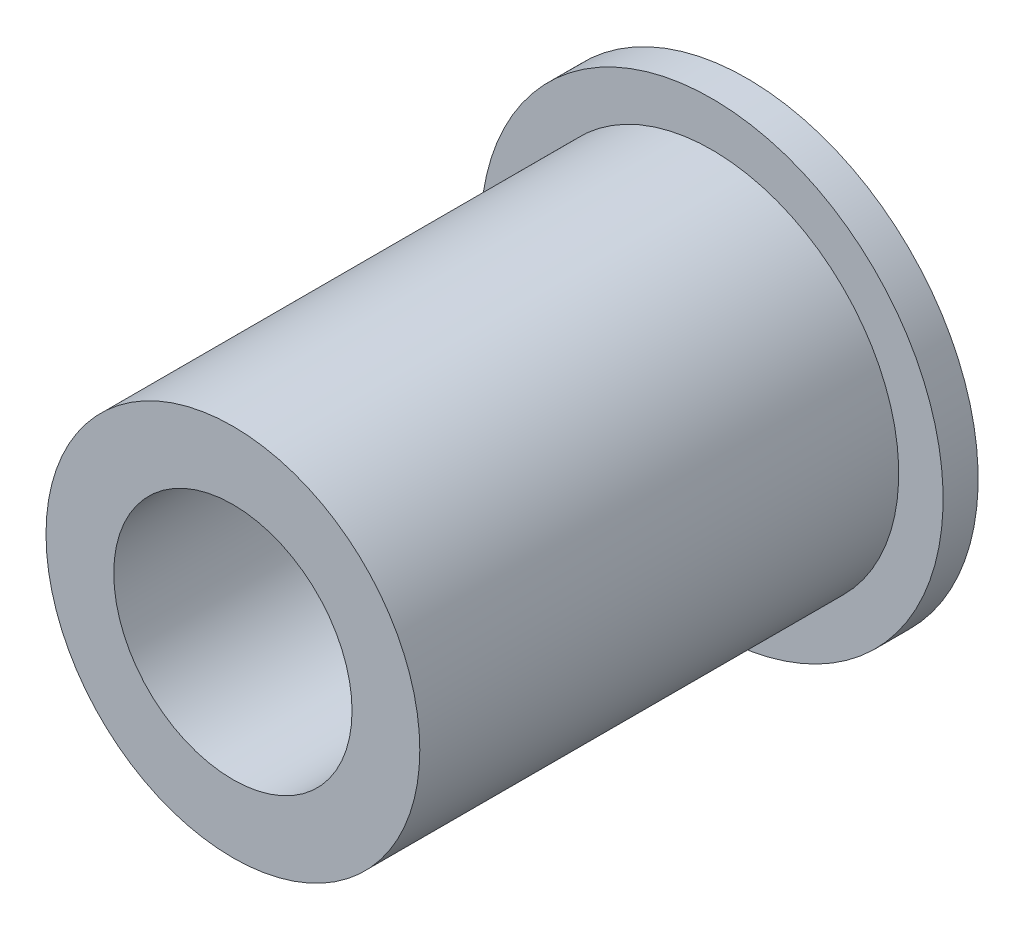
from build123d import *

# Parameters (mm, degrees)
SKETCH1_R           = 8
BOSS_EXTRUDE1_DEPTH = 22
SKETCH2_R           = 5.1
CUT_EXTRUDE1_DEPTH  = 13
SKETCH4_R           = 9.9
BOSS_EXTRUDE2_DEPTH = 1.5
CUT_EXTRUDE2_DEPTH  = 23


with BuildPart() as part:
    # Sketch1 → Boss-Extrude1 (new body)
    with BuildSketch(Plane.XY):
        Circle(SKETCH1_R)
    extrude(amount=BOSS_EXTRUDE1_DEPTH)

    # Sketch2 → Cut-Extrude1 (cut)
    with BuildSketch(Plane.XY.offset(22)):
        Circle(SKETCH2_R)
    extrude(amount=-CUT_EXTRUDE1_DEPTH, mode=Mode.SUBTRACT)

    # Sketch4 → Boss-Extrude2 (add)
    with BuildSketch(Plane(origin=(0, 0, 0), x_dir=(-1, 0, 0), z_dir=(0, 0, -1))):
        Circle(SKETCH4_R)
    extrude(amount=-BOSS_EXTRUDE2_DEPTH)

    # Sketch3 → Cut-Extrude2 (cut, through all)
    with BuildSketch(Plane(origin=(0, 0, 0), x_dir=(-1, 0, 0), z_dir=(0, 0, -1))):
        with BuildLine():
            Line((-0.858778202, 1.35), (0.858778202, 1.35))
            ThreePointArc((0.858778202, 1.35), (0, -1.6), (-0.858778202, 1.35))
        make_face()
    extrude(amount=-CUT_EXTRUDE2_DEPTH, mode=Mode.SUBTRACT)


solid = part.part
